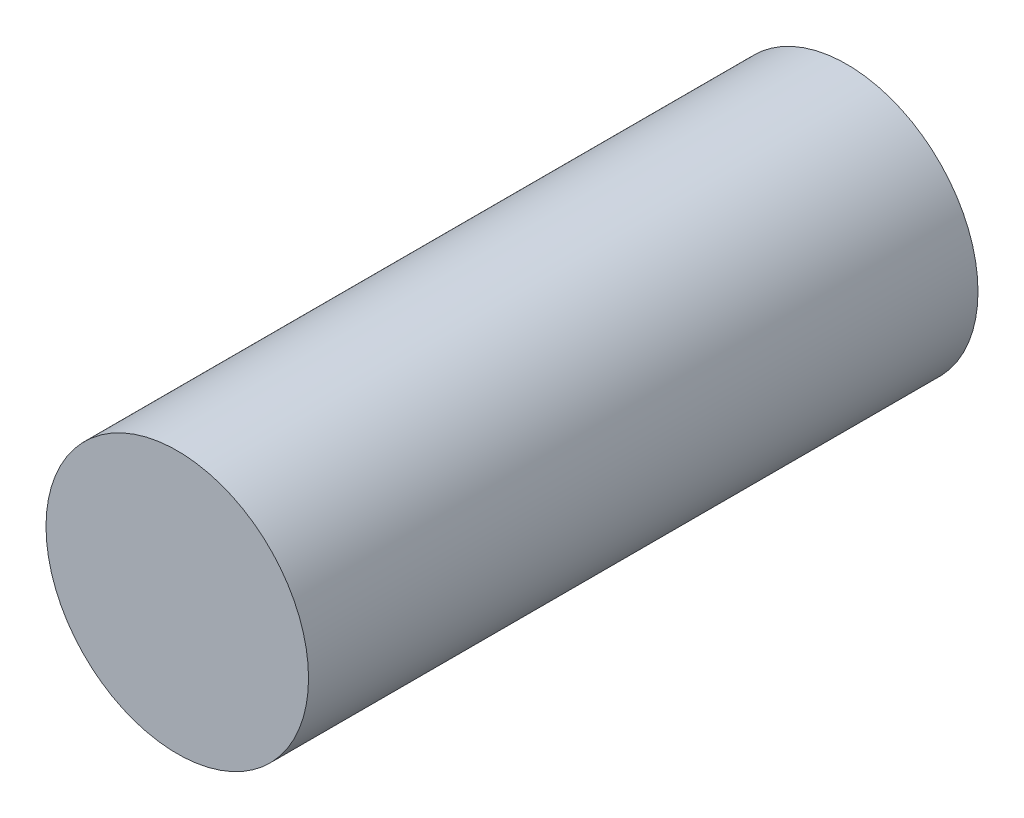
from build123d import *

# Parameters (mm, degrees)
SKETCH1_R           = 13
BOSS_EXTRUDE1_DEPTH = 66.3


with BuildPart() as part:
    # Sketch1 → Boss-Extrude1 (new body)
    with BuildSketch(Plane.XY):
        Circle(SKETCH1_R)
    extrude(amount=BOSS_EXTRUDE1_DEPTH)


solid = part.part
